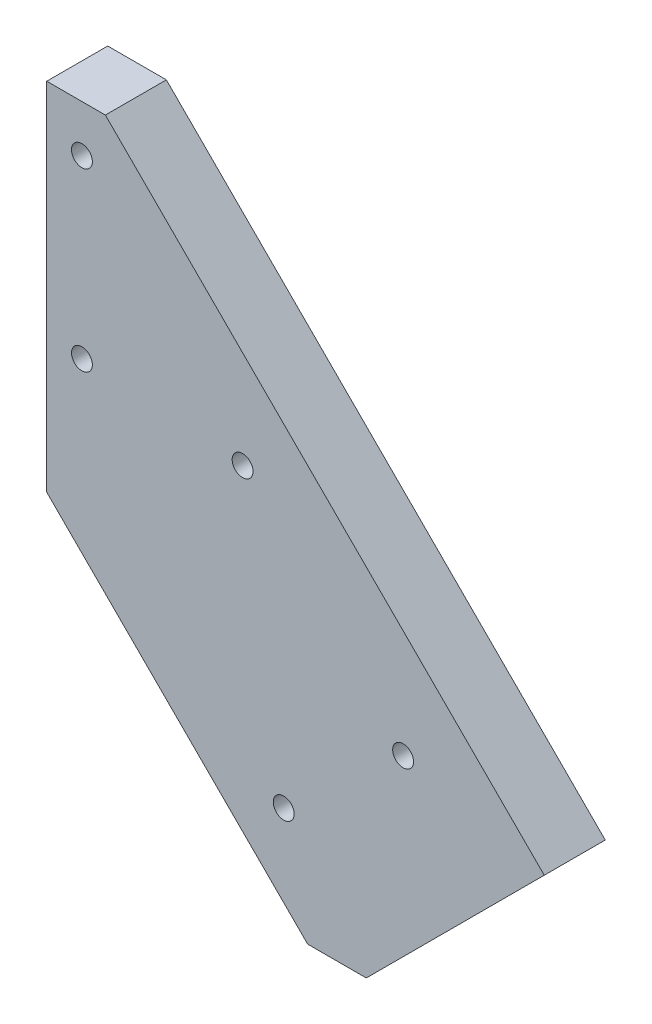
from build123d import *

# Parameters (mm, degrees)
BOSS_EXTRUDE1_DEPTH       = 6.604
F_4_40_TAPPED_HOLE1_D     = 2.2606
F_4_40_TAPPED_HOLE1_DEPTH = 7.5946
F_4_40_TAPPED_HOLE1_TIP   = 0.679152758
CUT_EXTRUDE1_DEPTH        = 7.604


with BuildPart() as part:
    # Sketch1 → Boss-Extrude1 (new body)
    with BuildSketch(Plane.XY):
        Polygon((6.35, -6.35), (53.881536726, -53.881536726), (31.430896424, -76.332177029), (0, -44.901280605), (0, -6.35), align=None)
    extrude(amount=BOSS_EXTRUDE1_DEPTH)

    # #4-40 Tapped Hole1
    with Locations(Plane.XY.offset(6.604)):
        with Locations((3.81, -11.43), (3.81, -30.48), (25.663262225, -61.689692887), (21.210222222, -31.794452992), (38.593017634, -50.314669612)):
            Hole(F_4_40_TAPPED_HOLE1_D / 2, depth=F_4_40_TAPPED_HOLE1_DEPTH)
            with Locations((0, 0, -(F_4_40_TAPPED_HOLE1_DEPTH + F_4_40_TAPPED_HOLE1_TIP / 2))):  # 118° drill point
                Cone(0, F_4_40_TAPPED_HOLE1_D / 2, F_4_40_TAPPED_HOLE1_TIP, mode=Mode.SUBTRACT)

    # Sketch5 → Cut-Extrude1 (cut, through all)
    with BuildSketch(Plane.XY.offset(6.604)):
        Polygon((34.605896424, -73.157177029), (28.255896424, -73.157177029), (31.430896424, -76.332177029), align=None)
    extrude(amount=-CUT_EXTRUDE1_DEPTH, mode=Mode.SUBTRACT)


solid = part.part
